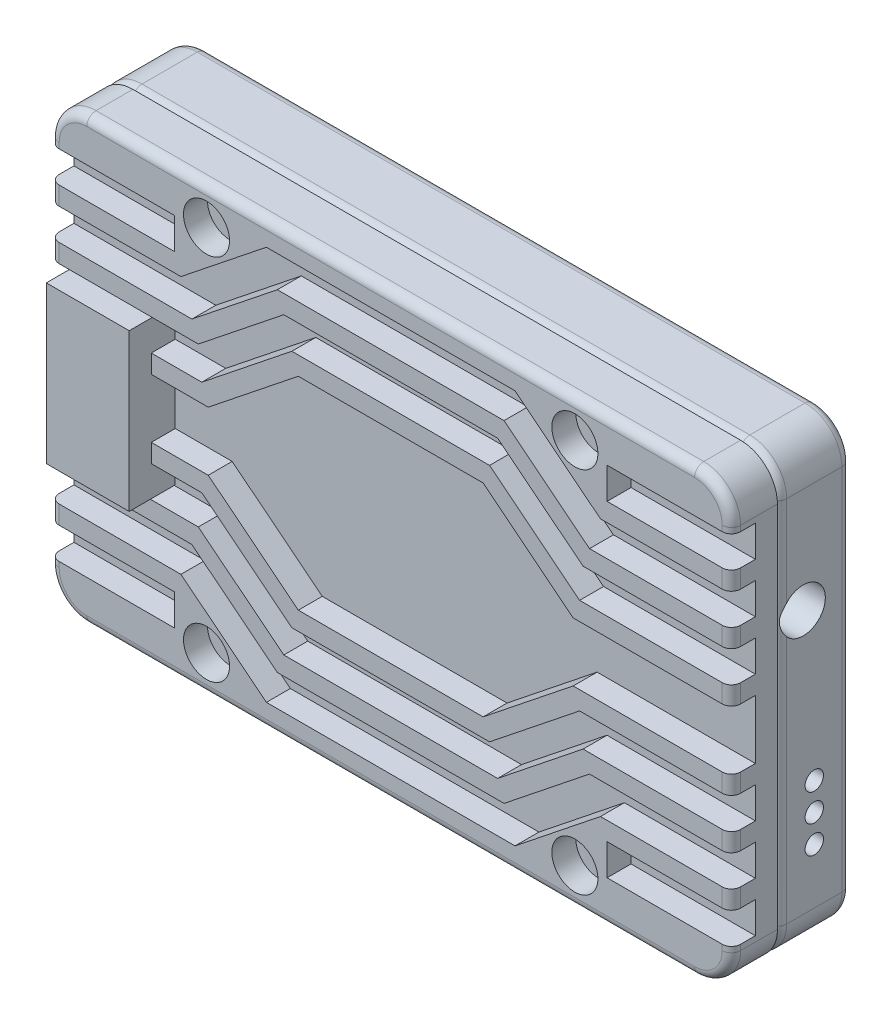
from build123d import *

# Parameters (mm, degrees)
BOSS_EXTRUDE1_DEPTH                        = 4
FILLET1_R                                  = 0.5
SKETCH3_R                                  = 1.2
BOSS_EXTRUDE3_DEPTH                        = 1.4
SKETCH8_R                                  = 1.2
SKETCH8_R_2                                = 0.5
CUT_EXTRUDE3_DEPTH                         = 2
BOSS_EXTRUDE2_DEPTH                        = 2.5
FILLET2_R                                  = 0.5
SKETCH6_R                                  = 1.25
SKETCH6_W                                  = 6.75
SKETCH6_H                                  = 1.7
CUT_EXTRUDE2_DEPTH                         = 1.3
MIRROR3_AT_THE_SECOND_PLANE_COPY_1_SKETC_R = 1.25
MIRROR3_AT_THE_SECOND_PLANE_COPY_1_SKETC_W = 6.75
MIRROR3_AT_THE_SECOND_PLANE_COPY_1_SKETC_H = 1.7
MIRROR3_AT_THE_SECOND_PLANE_COPY_1_DEPTH   = 1.3
CUT_EXTRUDE1_START                         = -2.5
SKETCH4_W                                  = 5.5
SKETCH4_H                                  = 8.5
CUT_EXTRUDE1_DEPTH                         = 2.5
BOSS_EXTRUDE4_DEPTH                        = 4.5
SKETCH7_W                                  = 3.7
SKETCH7_H                                  = 8.5
BOSS_EXTRUDE5_DEPTH                        = 2


with BuildPart() as part:
    # Sketch1 → Boss-Extrude1 (new body)
    with BuildSketch(Plane.XY):
        with BuildLine():
            Line((-16.5, 12), (16.5, 12))
            ThreePointArc((16.5, 12), (17.914213562, 11.414213562), (18.5, 10))
            Line((18.5, 10), (18.5, -10))
            ThreePointArc((18.5, -10), (17.914213562, -11.414213562), (16.5, -12))
            Line((16.5, -12), (-16.5, -12))
            ThreePointArc((-16.5, -12), (-17.914213562, -11.414213562), (-18.5, -10))
            Line((-18.5, -10), (-18.5, 10))
            ThreePointArc((-18.5, 10), (-17.914213562, 11.414213562), (-16.5, 12))
        make_face()
    extrude(amount=BOSS_EXTRUDE1_DEPTH)

    # Fillet1
    fillet1_edges = [part.edges().sort_by_distance(p)[0] for p in [
        (18.5, 0, 0),
        (17.914213562, -11.414213562, 0),
        (0, -12, 0),
        (-17.914213562, -11.414213562, 0),
        (17.914213562, -11.414213562, 4),
        (18.5, 0, 4),
        (17.914213562, 11.414213562, 4),
        (0, 12, 4),
        (-17.914213562, 11.414213562, 4),
        (-18.5, 0, 4),
        (-17.914213562, -11.414213562, 4),
        (-18.5, 0, 0),
        (0, -12, 4),
        (-17.914213562, 11.414213562, 0),
        (0, 12, 0),
        (17.914213562, 11.414213562, 0),
    ]]
    fillet(fillet1_edges, radius=FILLET1_R)

    # Sketch3 → Boss-Extrude3 (add)
    with BuildSketch(Plane.XZ.offset(12)):
        with Locations((-10, 2)):
            Circle(SKETCH3_R)
        with Locations((10, 2)):
            Circle(SKETCH3_R)
    extrude(amount=BOSS_EXTRUDE3_DEPTH)

    # Sketch8 → Cut-Extrude3 (cut)
    with BuildSketch(Plane(origin=(18.5, 0, 0), x_dir=(0, 0, -1), z_dir=(1, 0, 0))):
        with Locations((-2.6, 4.3)):
            Circle(SKETCH8_R)
        with Locations((-2, -4)):
            Circle(SKETCH8_R_2)
        with Locations((-2, -5.5)):
            Circle(SKETCH8_R_2)
        with Locations((-2, -7)):
            Circle(SKETCH8_R_2)
    extrude(amount=-CUT_EXTRUDE3_DEPTH, mode=Mode.SUBTRACT)


with BuildPart() as body_2:
    # Sketch2 → Boss-Extrude2 (new body)
    with BuildSketch(Plane.XY.offset(4)):
        with BuildLine():
            Line((-18.5, 10), (-18.5, -10))
            ThreePointArc((-18.5, -10), (-17.914213562, -11.414213562), (-16.5, -12))
            Line((-16.5, -12), (16.5, -12))
            ThreePointArc((16.5, -12), (17.914213562, -11.414213562), (18.5, -10))
            Line((18.5, -10), (18.5, 10))
            ThreePointArc((18.5, 10), (17.914213562, 11.414213562), (16.5, 12))
            Line((16.5, 12), (-16.5, 12))
            ThreePointArc((-16.5, 12), (-17.914213562, 11.414213562), (-18.5, 10))
        make_face()
    extrude(amount=BOSS_EXTRUDE2_DEPTH)

    # Fillet2
    fillet2_edges = [body_2.edges().sort_by_distance(p)[0] for p in [
        (-17.914213562, -11.414213562, 6.5),
        (0, -12, 6.5),
        (17.914213562, -11.414213562, 6.5),
        (18.5, 0, 6.5),
        (17.914213562, 11.414213562, 6.5),
        (0, 12, 6.5),
        (-17.914213562, 11.414213562, 6.5),
        (-18.5, 0, 6.5),
    ]]
    fillet(fillet2_edges, radius=FILLET2_R)

    # Sketch6 → Cut-Extrude2 (cut)
    with BuildSketch(Plane.XY.offset(6.5)):
        with Locations((10, 10)):
            Circle(SKETCH6_R)
        Polygon((0, 10.7), (6.75, 10.7), (11.39, 7), (18.5, 7), (18.5, 5.3), (10.795179029, 5.3), (6.155179029, 9), (0, 9), align=None)
        Polygon((0, 6.5), (5.366992048, 6.5), (10.257802859, 2.6), (18.5, 2.6), (18.5, 4.3), (10.44528434, 4.3), (5.80528434, 8), (0, 8), align=None)
        Polygon((0, 5.5), (5.017097359, 5.5), (9.90790817, 1.6), (18.5, 1.6), (18.5, 0), (0, 0), align=None)
        with Locations((15.125, 8.85)):
            Rectangle(SKETCH6_W, SKETCH6_H)
    cut_extrude2 = extrude(amount=-CUT_EXTRUDE2_DEPTH, mode=Mode.SUBTRACT)

    # Mirror3: Cut-Extrude2 across plane
    add(cut_extrude2.mirror(Plane(origin=(0, 0, 0), x_dir=(0, 0, 1), z_dir=(1, 0, 0))), mode=Mode.SUBTRACT)

    # Mirror3 at the second plane: Cut-Extrude2 across plane
    add(cut_extrude2.mirror(Plane.ZX), mode=Mode.SUBTRACT)

    # Mirror3 at the second plane copy 1 sketc → Mirror3 at the second plane copy 1 (cut)
    with BuildSketch(Plane(origin=(0, 0, 6.5), x_dir=(-1, 0, 0), z_dir=(0, 0, 1))):
        with Locations((10, 10)):
            Circle(MIRROR3_AT_THE_SECOND_PLANE_COPY_1_SKETC_R)
        Polygon((0, 10.7), (6.75, 10.7), (11.39, 7), (18.5, 7), (18.5, 5.3), (10.795179029, 5.3), (6.155179029, 9), (0, 9), align=None)
        Polygon((0, 6.5), (5.366992048, 6.5), (10.257802859, 2.6), (18.5, 2.6), (18.5, 4.3), (10.44528434, 4.3), (5.80528434, 8), (0, 8), align=None)
        Polygon((0, 5.5), (5.017097359, 5.5), (9.90790817, 1.6), (18.5, 1.6), (18.5, 0), (0, 0), align=None)
        with Locations((15.125, 8.85)):
            Rectangle(MIRROR3_AT_THE_SECOND_PLANE_COPY_1_SKETC_W, MIRROR3_AT_THE_SECOND_PLANE_COPY_1_SKETC_H)
    extrude(amount=-MIRROR3_AT_THE_SECOND_PLANE_COPY_1_DEPTH, mode=Mode.SUBTRACT)

    # Sketch4 → Cut-Extrude1 (cut)
    with BuildSketch(Plane.XY.offset(6.5).offset(CUT_EXTRUDE1_START)):
        with Locations((-15.75, 0)):
            Rectangle(SKETCH4_W, SKETCH4_H)
    extrude(amount=CUT_EXTRUDE1_DEPTH, mode=Mode.SUBTRACT)


with BuildPart() as body_3:
    # Sketch5 → Boss-Extrude4 (new body)
    with BuildSketch(Plane.ZY.offset(13)):
        Polygon((7.7, 4.25), (5, 4.25), (5, 3.75), (4, 3.75), (4, -3.75), (5, -3.75), (5, -4.25), (7.7, -4.25), align=None)
        Polygon((7.4, 3.95), (5.3, 3.95), (5.3, 3.45), (4.3, 3.45), (4.3, -3.45), (5.3, -3.45), (5.3, -3.95), (7.4, -3.95), align=None, mode=Mode.SUBTRACT)
    extrude(amount=BOSS_EXTRUDE4_DEPTH)

    # Sketch7 → Boss-Extrude5 (add)
    with BuildSketch(Plane(origin=(-13, 0, 0), x_dir=(0, 0, -1), z_dir=(1, 0, 0))):
        with Locations((-5.85, 0)):
            Rectangle(SKETCH7_W, SKETCH7_H)
    extrude(amount=-BOSS_EXTRUDE5_DEPTH)


solid = Compound([part.part, body_2.part, body_3.part])
